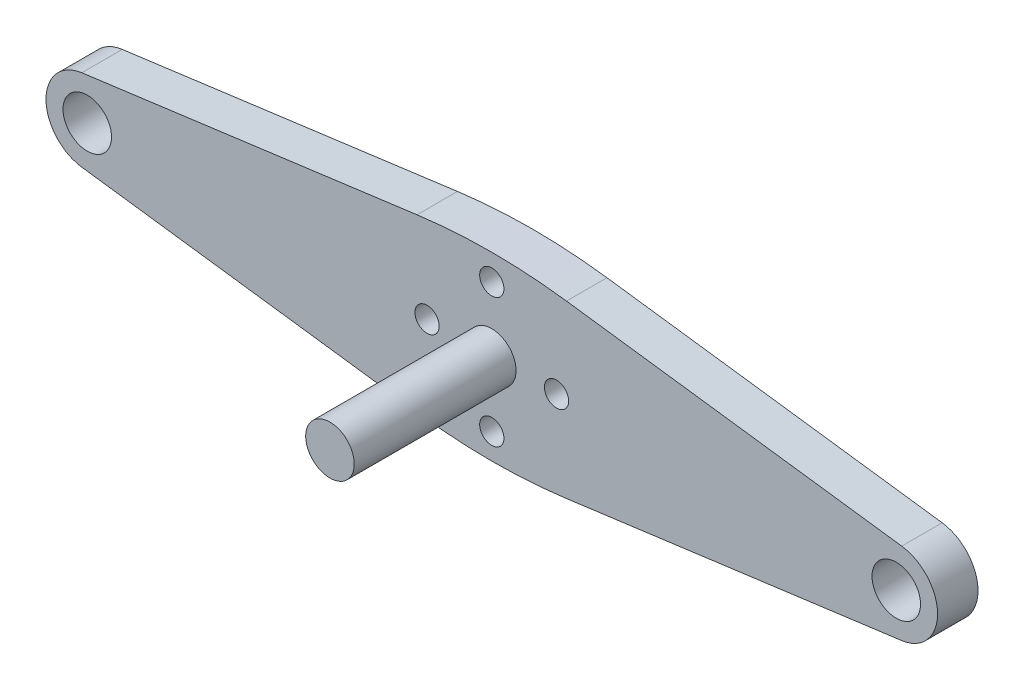
from build123d import *

# Parameters (mm, degrees)
SZKIC1_R                    = 3
SZKIC1_R_2                  = 1.5
DODANIE_WYCI_GNI_CIE1_DEPTH = 5
SZKIC1_2_R                  = 3
DODANIE_WYCI_GNI_CIE2_DEPTH = 25


with BuildPart() as part:
    # Szkic1 → Dodanie-wyci_gni_cie1 (new body)
    with BuildSketch(Plane.XY):
        with BuildLine():
            Line((-50.67287635, 5.055665151), (-9.235111676, 10.570763761))
            ThreePointArc((-9.235111676, 10.570763761), (0, 11.182632843), (9.235111676, 10.570763761))
            Line((9.235111676, 10.570763761), (50.67287635, 5.055665151))
            ThreePointArc((50.67287635, 5.055665151), (55.100246338, 0), (50.67287635, -5.055665151))
            Line((50.67287635, -5.055665151), (9.235111676, -10.570763761))
            ThreePointArc((9.235111676, -10.570763761), (0, -11.182632843), (-9.235111676, -10.570763761))
            Line((-9.235111676, -10.570763761), (-50.67287635, -5.055665151))
            ThreePointArc((-50.67287635, -5.055665151), (-55.100246338, 0), (-50.67287635, 5.055665151))
        make_face()
        Circle(SZKIC1_R, mode=Mode.SUBTRACT)
        with Locations((0, 8)):
            Circle(SZKIC1_R_2, mode=Mode.SUBTRACT)
        with Locations((-8, 0)):
            Circle(SZKIC1_R_2, mode=Mode.SUBTRACT)
        with Locations((8, 0)):
            Circle(SZKIC1_R_2, mode=Mode.SUBTRACT)
        with Locations((0, -8)):
            Circle(SZKIC1_R_2, mode=Mode.SUBTRACT)
        with Locations((-50, 0)):
            Circle(SZKIC1_R, mode=Mode.SUBTRACT)
        with Locations((50, 0)):
            Circle(SZKIC1_R, mode=Mode.SUBTRACT)
    extrude(amount=DODANIE_WYCI_GNI_CIE1_DEPTH)

    # Szkic1_2 → Dodanie-wyci_gni_cie2 (add)
    with BuildSketch(Plane.XY):
        Circle(SZKIC1_2_R)
    extrude(amount=DODANIE_WYCI_GNI_CIE2_DEPTH)


solid = part.part
